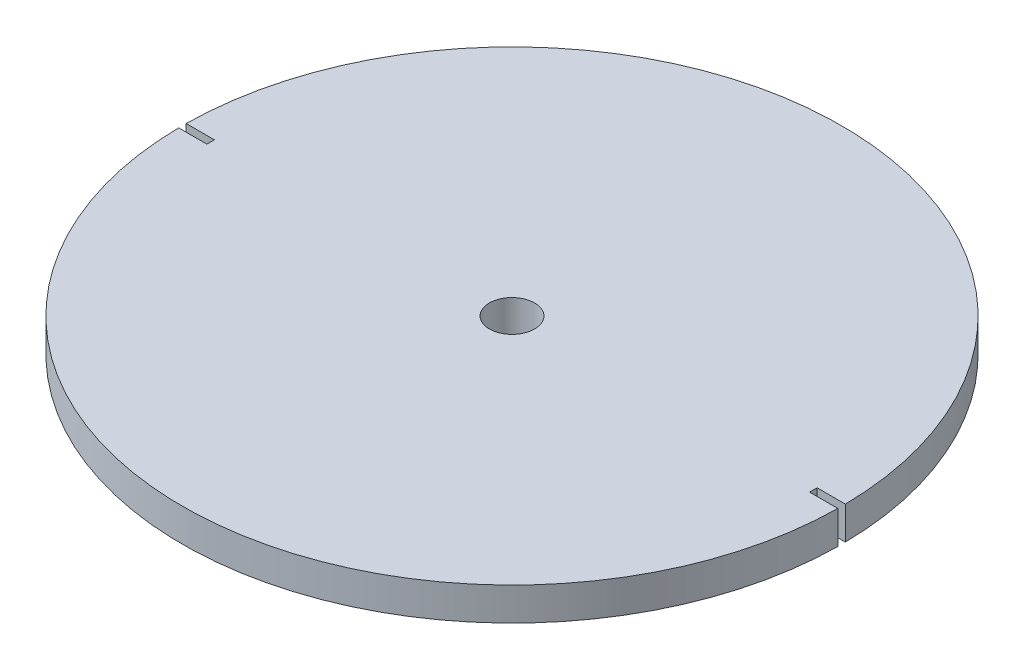
from build123d import *

# Parameters (mm, degrees)
SKETCH_3_R          = 35
EXTRUDE_1_DEPTH     = 3.5
CUT_EXTRUDE_5_DEPTH = 1.2
SKETCH_4_W          = 5
SKETCH_4_H          = 0.8
CUT_EXTRUDE_6_DEPTH = 50.621064076
SKETCH_5_R          = 2.4
CUT_EXTRUDE_7_DEPTH = 50.619451831


with BuildPart() as part:
    # 스케치3 → 보스-돌출1 (new body)
    with BuildSketch(Plane(origin=(0, 0, 0), x_dir=(1, 0, 0), z_dir=(0, 1, 0))):
        Circle(SKETCH_3_R)
    extrude(amount=EXTRUDE_1_DEPTH)

    # 스케치1 → 컷-돌출5 (cut)
    # profile 1 of 4: a face of its own
    with BuildSketch(Plane(origin=(0, 0, 0), x_dir=(1, 0, 0), z_dir=(0, 1, 0))):
        Polygon((-12.628553268, -30.488024573), (12.628553268, -30.488024573), (30.488024573, -12.628553268), (30.488024573, 12.628553268), (12.628553268, 30.488024573), (-12.628553268, 30.488024573), (-30.488024573, 12.628553268), (-30.488024573, -12.628553268), align=None)
        Polygon((29.488024573, -12.214339706), (12.214339706, -29.488024573), (-12.214339706, -29.488024573), (-29.488024573, -12.214339706), (-29.488024573, 12.214339706), (-12.214339706, 29.488024573), (12.214339706, 29.488024573), (29.488024573, 12.214339706), align=None, mode=Mode.SUBTRACT)
    # profile 2 of 4: a face of its own
    with BuildSketch(Plane(origin=(0, 0, 0), x_dir=(1, 0, 0), z_dir=(0, 1, 0))):
        Polygon((-25.86862691, -10.715136106), (-10.715136106, -25.86862691), (10.715136106, -25.86862691), (25.86862691, -10.715136106), (25.86862691, 10.715136106), (10.715136106, 25.86862691), (-10.715136106, 25.86862691), (-25.86862691, 10.715136106), align=None)
        Polygon((10.300922544, -24.86862691), (-10.300922544, -24.86862691), (-24.86862691, -10.300922544), (-24.86862691, 10.300922544), (-10.300922544, 24.86862691), (10.300922544, 24.86862691), (24.86862691, 10.300922544), (24.86862691, -10.300922544), align=None, mode=Mode.SUBTRACT)
    # profile 3 of 4: a face of its own
    with BuildSketch(Plane(origin=(0, 0, 0), x_dir=(1, 0, 0), z_dir=(0, 1, 0))):
        Polygon((-8.706048086, -21.018259365), (8.706048086, -21.018259365), (21.018259365, -8.706048086), (21.018259365, 8.706048086), (8.706048086, 21.018259365), (-8.706048086, 21.018259365), (-21.018259365, 8.706048086), (-21.018259365, -8.706048086), align=None)
        Polygon((20.018259365, -8.291834524), (8.291834524, -20.018259365), (-8.291834524, -20.018259365), (-20.018259365, -8.291834524), (-20.018259365, 8.291834524), (-8.291834524, 20.018259365), (8.291834524, 20.018259365), (20.018259365, 8.291834524), align=None, mode=Mode.SUBTRACT)
    # profile 4 of 4: a face of its own
    with BuildSketch(Plane(origin=(0, 0, 0), x_dir=(1, 0, 0), z_dir=(0, 1, 0))):
        Polygon((-6.888301783, -16.629831585), (6.888301783, -16.629831585), (16.629831585, -6.888301783), (16.629831585, 6.888301783), (6.888301783, 16.629831585), (-6.888301783, 16.629831585), (-16.629831585, 6.888301783), (-16.629831585, -6.888301783), align=None)
        Polygon((15.629831585, -6.47408822), (6.47408822, -15.629831585), (-6.47408822, -15.629831585), (-15.629831585, -6.47408822), (-15.629831585, 6.47408822), (-6.47408822, 15.629831585), (6.47408822, 15.629831585), (15.629831585, 6.47408822), align=None, mode=Mode.SUBTRACT)
    extrude(amount=CUT_EXTRUDE_5_DEPTH, mode=Mode.SUBTRACT)

    # 스케치4 → 컷-돌출6 (cut, through all)
    with BuildSketch(Plane(origin=(0, 3.5, 0), x_dir=(1, 0, 0), z_dir=(0, 1, 0))):
        with Locations((-34.5, 0)):
            Rectangle(SKETCH_4_W, SKETCH_4_H)
        with Locations((34.5, 0)):
            Rectangle(SKETCH_4_W, SKETCH_4_H)
    extrude(amount=-CUT_EXTRUDE_6_DEPTH, mode=Mode.SUBTRACT)

    # 스케치5 → 컷-돌출7 (cut, through all)
    with BuildSketch(Plane(origin=(0, 3.5, 0), x_dir=(1, 0, 0), z_dir=(0, 1, 0))):
        Circle(SKETCH_5_R)
    extrude(amount=-CUT_EXTRUDE_7_DEPTH, mode=Mode.SUBTRACT)


solid = part.part
